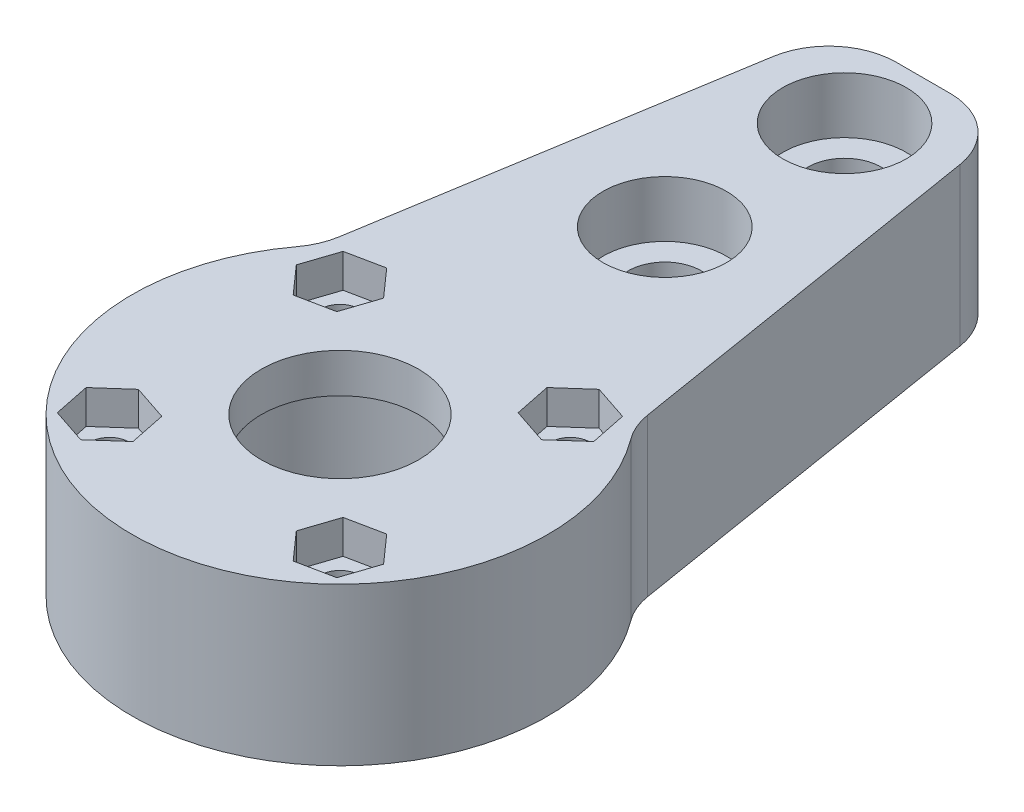
from build123d import *

# Parameters (mm, degrees)
SKETCH1_R           = 7
BOSS_EXTRUDE1_DEPTH = 14
SKETCH2_R           = 11.075
CUT_EXTRUDE1_DEPTH  = 10.5
SKETCH4_R           = 1.75
CUT_EXTRUDE4_DEPTH  = 15
CUT_EXTRUDE5_DEPTH  = 3
SKETCH6_R           = 3.25
CUT_EXTRUDE6_DEPTH  = 15
SKETCH7_R           = 5.5
CUT_EXTRUDE7_DEPTH  = 5
FILLET4_R           = 6


with BuildPart() as part:
    # Sketch1 → Boss-Extrude1 (new body)
    with BuildSketch(Plane(origin=(0, 0, 0), x_dir=(1, 0, 0), z_dir=(0, 1, 0))):
        with BuildLine():
            Line((-7.5, 51.911534525), (7.5, 51.911534525))
            Line((7.5, 51.911534525), (13.985690309, 12.109932558))
            ThreePointArc((13.985690309, 12.109932558), (0, -18.5), (-13.985690309, 12.109932558))
            Line((-13.985690309, 12.109932558), (-7.5, 51.911534525))
        make_face()
        Circle(SKETCH1_R, mode=Mode.SUBTRACT)
    extrude(amount=BOSS_EXTRUDE1_DEPTH)

    # Sketch2 → Cut-Extrude1 (cut)
    with BuildSketch(Plane.XZ):
        Circle(SKETCH2_R)
    extrude(amount=-CUT_EXTRUDE1_DEPTH, mode=Mode.SUBTRACT)

    # Sketch4 → Cut-Extrude4 (cut, through all)
    with BuildSketch(Plane.XZ):
        with Locations((10.253048327, 10.253048327)):
            Circle(SKETCH4_R)
        with Locations((10.253048327, -10.253048327)):
            Circle(SKETCH4_R)
        with Locations((-10.253048327, -10.253048327)):
            Circle(SKETCH4_R)
        with Locations((-10.253048327, 10.253048327)):
            Circle(SKETCH4_R)
    extrude(amount=-CUT_EXTRUDE4_DEPTH, mode=Mode.SUBTRACT)

    # Sketch5 → Cut-Extrude5 (cut)
    with BuildSketch(Plane(origin=(0, 14, 0), x_dir=(1, 0, 0), z_dir=(0, 1, 0))):
        Polygon((13.375361377, 9.2132593), (12.714688564, 12.437156233), (9.592375514, 13.47694526), (7.130735278, 11.292837354), (7.79140809, 8.068940421), (10.91372114, 7.029151394), align=None)
        Polygon((-9.2132593, 13.375361377), (-12.437156233, 12.714688564), (-13.47694526, 9.592375514), (-11.292837354, 7.130735278), (-8.068940421, 7.79140809), (-7.029151394, 10.91372114), align=None)
        Polygon((9.2132593, -13.375361377), (12.437156233, -12.714688564), (13.47694526, -9.592375514), (11.292837354, -7.130735278), (8.068940421, -7.79140809), (7.029151394, -10.91372114), align=None)
        Polygon((-13.375361377, -9.2132593), (-12.714688564, -12.437156233), (-9.592375514, -13.47694526), (-7.130735278, -11.292837354), (-7.79140809, -8.068940421), (-10.91372114, -7.029151394), align=None)
    extrude(amount=-CUT_EXTRUDE5_DEPTH, mode=Mode.SUBTRACT)

    # Sketch6 → Cut-Extrude6 (cut, through all)
    with BuildSketch(Plane(origin=(0, 14, 0), x_dir=(1, 0, 0), z_dir=(0, 1, 0))):
        with Locations((0, 44.911534525)):
            Circle(SKETCH6_R)
        with Locations((0, 28.911534525)):
            Circle(SKETCH6_R)
    extrude(amount=-CUT_EXTRUDE6_DEPTH, mode=Mode.SUBTRACT)

    # Sketch7 → Cut-Extrude7 (cut)
    with BuildSketch(Plane(origin=(0, 14, 0), x_dir=(1, 0, 0), z_dir=(0, 1, 0))):
        with Locations((0, 28.911534525)):
            Circle(SKETCH7_R)
        with Locations((0, 44.911534525)):
            Circle(SKETCH7_R)
    extrude(amount=-CUT_EXTRUDE7_DEPTH, mode=Mode.SUBTRACT)

    # Fillet4
    fillet4_edges = [part.edges().sort_by_distance(p)[0] for p in [
        (-7.5, 7, -51.911534525),
        (7.5, 7, -51.911534525),
        (13.985690309, 7, -12.109932558),
        (-13.985690309, 7, -12.109932558),
    ]]
    fillet(fillet4_edges, radius=FILLET4_R)


solid = part.part
